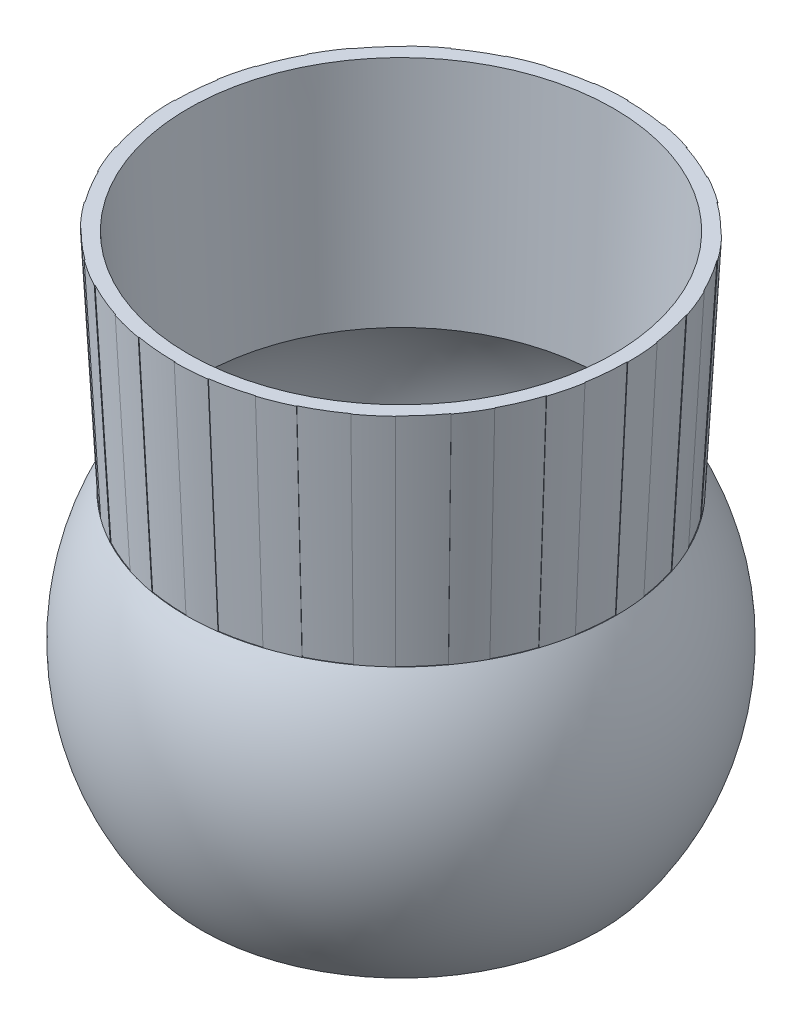
from build123d import *

# Parameters (mm, degrees)
CUT_REVOLVE1_ANGLE = 10
CIRPATTERN1_COUNT  = 20


with BuildPart() as part:
    # Sketch1 → Revolve1 (revolve)
    with BuildSketch(Plane(origin=(0, 0, 0), x_dir=(0, 0, -1), z_dir=(1, 0, 0))):
        with BuildLine():
            Line((45, 0), (42.5, -47.702841719))
            ThreePointArc((42.5, -47.702841719), (50.222540624, -76.742912379), (40, -105))
            Line((40, -105), (42.121320344, -107.121320344))
            ThreePointArc((42.121320344, -107.121320344), (52.934042404, -77.930858803), (45.5, -47.702841719))
            Line((45.5, -47.702841719), (48, 0))
            Line((48, 0), (45, 0))
        make_face()
    revolve(axis=Axis((0, 50.355486862, 0), (0, -1, 0)))

    # Sketch2 → Cut-Revolve1 (revolve, cut)
    with BuildSketch(Plane.XY):
        Polygon((48, 0), (45.5, -47.702841719), (45.374828457, -47.702841719), (47.874828457, 0), align=None)
    cut_revolve1 = revolve(axis=Axis((0, 0, 0), (0, -1, 0)), revolution_arc=CUT_REVOLVE1_ANGLE, mode=Mode.SUBTRACT)

    # CirPattern1: Cut-Revolve1 ×20 about axis
    cirpattern1_axis = Axis((0, 0, 0), (0, 1, 0))
    for i in range(1, CIRPATTERN1_COUNT):
        add(cut_revolve1.rotate(cirpattern1_axis, i * 360 / CIRPATTERN1_COUNT), mode=Mode.SUBTRACT)


solid = part.part
